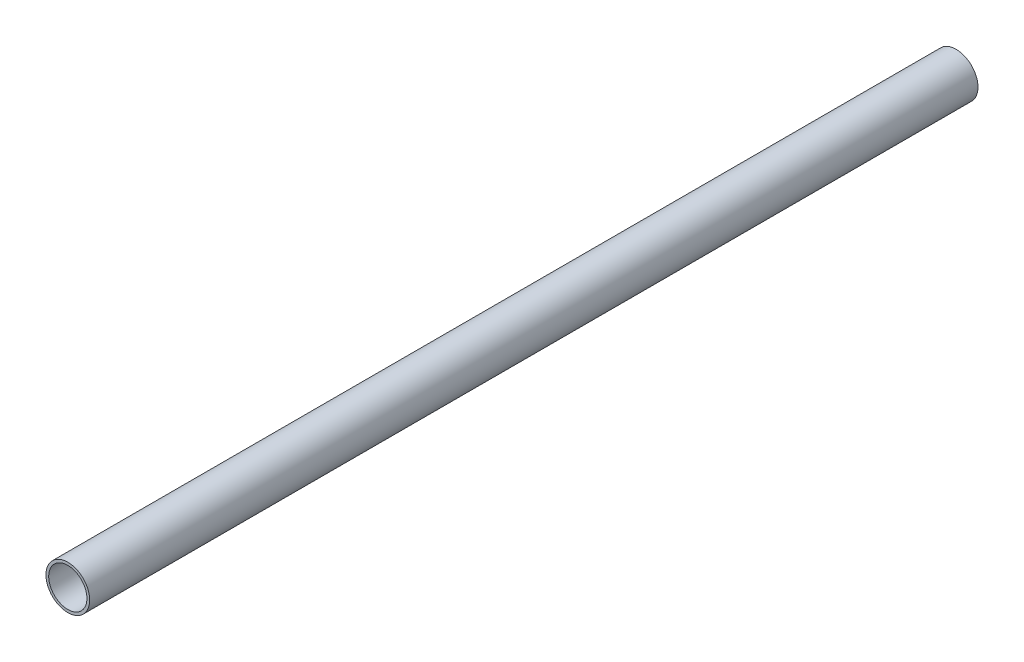
from build123d import *

# Parameters (mm, degrees)
SKETCH1_R           = 8
SKETCH1_R_2         = 7
BOSS_EXTRUDE1_DEPTH = 325.28


with BuildPart() as part:
    # Sketch1 → Boss-Extrude1 (new body)
    with BuildSketch(Plane.XY):
        Circle(SKETCH1_R)
        Circle(SKETCH1_R_2, mode=Mode.SUBTRACT)
    extrude(amount=BOSS_EXTRUDE1_DEPTH)


solid = part.part
